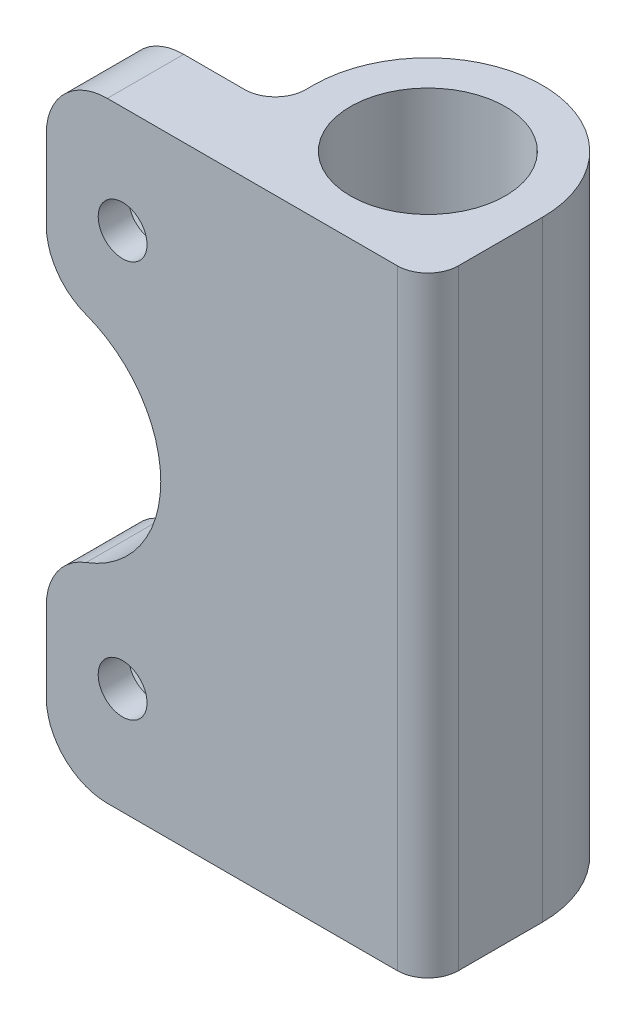
from build123d import *

# Parameters (mm, degrees)
CROQUIS1_R              = 5.075
SALIENTE_EXTRUIR1_DEPTH = 40
CROQUIS2_R              = 1.6
CORTAR_EXTRUIR1_DEPTH   = 6
CORTAR_EXTRUIR2_DEPTH   = 3
CORTAR_EXTRUIR3_DEPTH   = 6
REDONDEO1_R             = 4
REDONDEO2_R             = 2


with BuildPart() as part:
    # Croquis1 → Saliente-Extruir1 (new body)
    with BuildSketch(Plane(origin=(0, 0, 0), x_dir=(1, 0, 0), z_dir=(0, 1, 0))):
        with BuildLine():
            Line((-17.5, -7.5), (7.5, -7.5))
            Line((7.5, -7.5), (7.5, 0))
            ThreePointArc((7.5, 0), (0, 7.5), (-7.5, 0))
            Line((-7.5, 0), (-7.5, -2.5))
            Line((-7.5, -2.5), (-17.5, -2.5))
            Line((-17.5, -2.5), (-17.5, -7.5))
        make_face()
        Circle(CROQUIS1_R, mode=Mode.SUBTRACT)
    extrude(amount=SALIENTE_EXTRUIR1_DEPTH)

    # Croquis2 → Cortar-Extruir1 (cut, through all)
    with BuildSketch(Plane(origin=(0, 0, 2.5), x_dir=(-1, 0, 0), z_dir=(0, 0, -1))):
        with Locations((12.5, 7)):
            Circle(CROQUIS2_R)
        with Locations((12.5, 33)):
            Circle(CROQUIS2_R)
    extrude(amount=-CORTAR_EXTRUIR1_DEPTH, mode=Mode.SUBTRACT)

    # Croquis3 → Cortar-Extruir2 (cut)
    with BuildSketch(Plane(origin=(0, 0, 2.5), x_dir=(-1, 0, 0), z_dir=(0, 0, -1))):
        Polygon((15.3, 31.383419246), (15.3, 34.616580754), (12.5, 36.233161507), (9.7, 34.616580754), (9.7, 31.383419246), (12.5, 29.766838493), align=None)
        Polygon((12.5, 10.233161507), (15.3, 8.616580754), (15.3, 5.383419246), (12.5, 3.766838493), (9.7, 5.383419246), (9.7, 8.616580754), align=None)
    extrude(amount=-CORTAR_EXTRUIR2_DEPTH, mode=Mode.SUBTRACT)

    # Croquis4 → Cortar-Extruir3 (cut, through all)
    with BuildSketch(Plane(origin=(0, 0, 2.5), x_dir=(-1, 0, 0), z_dir=(0, 0, -1))):
        with BuildLine():
            Line((17.5, 27.5), (17.5, 12.5))
            ThreePointArc((17.5, 12.5), (10, 20), (17.5, 27.5))
        make_face()
    extrude(amount=-CORTAR_EXTRUIR3_DEPTH, mode=Mode.SUBTRACT)

    # Redondeo1
    redondeo1_edges = [part.edges().sort_by_distance(p)[0] for p in [
        (-17.5, 40, 5),
        (-17.5, 12.5, 5),
        (-17.5, 27.5, 5),
        (-17.5, 0, 5),
    ]]
    fillet(redondeo1_edges, radius=REDONDEO1_R)

    # Redondeo2
    redondeo2_edges = [part.edges().sort_by_distance(p)[0] for p in [
        (-7.5, 20, 2.5),
        (7.5, 20, 7.5),
    ]]
    fillet(redondeo2_edges, radius=REDONDEO2_R)


solid = part.part
